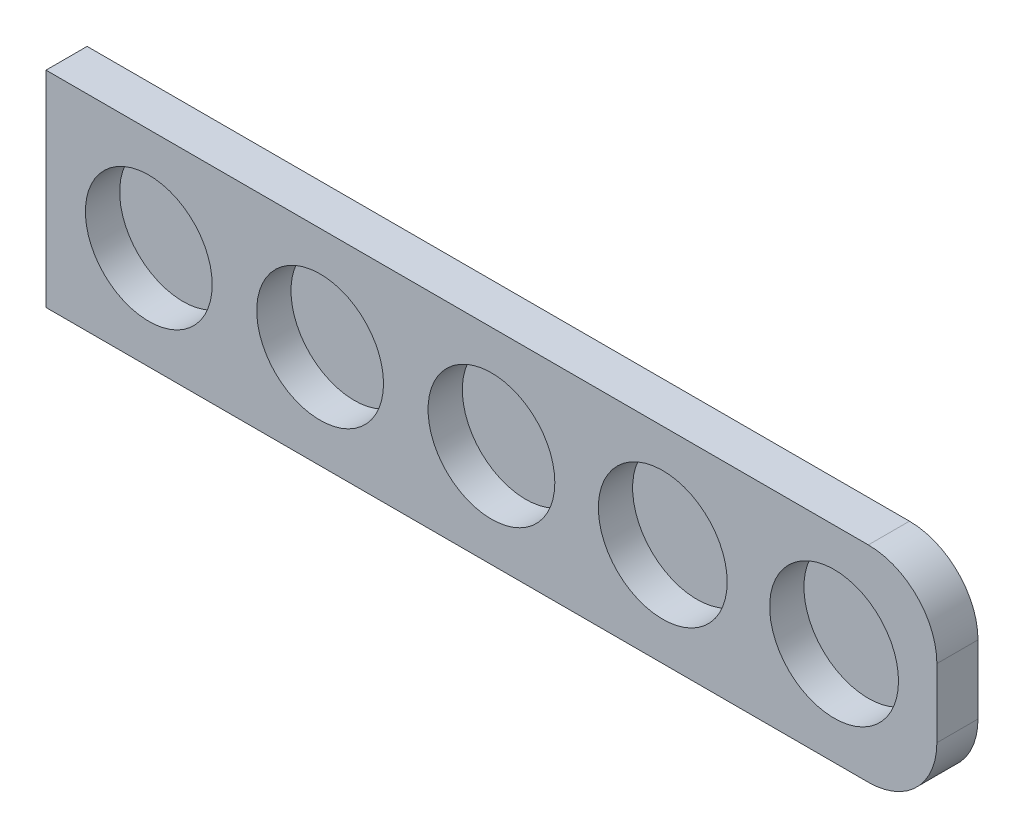
from build123d import *

# Parameters (mm, degrees)
SKETCH_1_W                    = 130
SKETCH_1_H                    = 30
EXTRUDE_1_DEPTH               = 6
HOLE_WIZARD_M16_1_D           = 18.8
HOLE_WIZARD_M16_1_DEPTH       = 5
HOLE_WIZARD_18_5_18_5_1_D     = 18.5
HOLE_WIZARD_18_5_18_5_1_DEPTH = 5
FILLET_1_R                    = 10


with BuildPart() as part:
    # 草图1 → 凸台-拉伸1 (new body)
    with BuildSketch(Plane(origin=(0, 0, 0), x_dir=(-1, 0, 0), z_dir=(0, 0, -1))):
        with Locations((-65, -71)):
            Rectangle(SKETCH_1_W, SKETCH_1_H)
    extrude(amount=-EXTRUDE_1_DEPTH)

    # M16 间隙孔1
    with Locations(Plane.XY.offset(6)):
        with Locations((90, -71), (115, -71)):
            Hole(HOLE_WIZARD_M16_1_D / 2, depth=HOLE_WIZARD_M16_1_DEPTH)

    # Ø18.5 (18.5) 直径孔1
    with Locations(Plane.XY.offset(6)):
        with Locations((15, -71), (40, -71), (65, -71)):
            Hole(HOLE_WIZARD_18_5_18_5_1_D / 2, depth=HOLE_WIZARD_18_5_18_5_1_DEPTH)

    # 圆角1
    fillet_1_edges = [part.edges().sort_by_distance(p)[0] for p in [
        (130, -86, 3),
        (130, -56, 3),
    ]]
    fillet(fillet_1_edges, radius=FILLET_1_R)


solid = part.part
